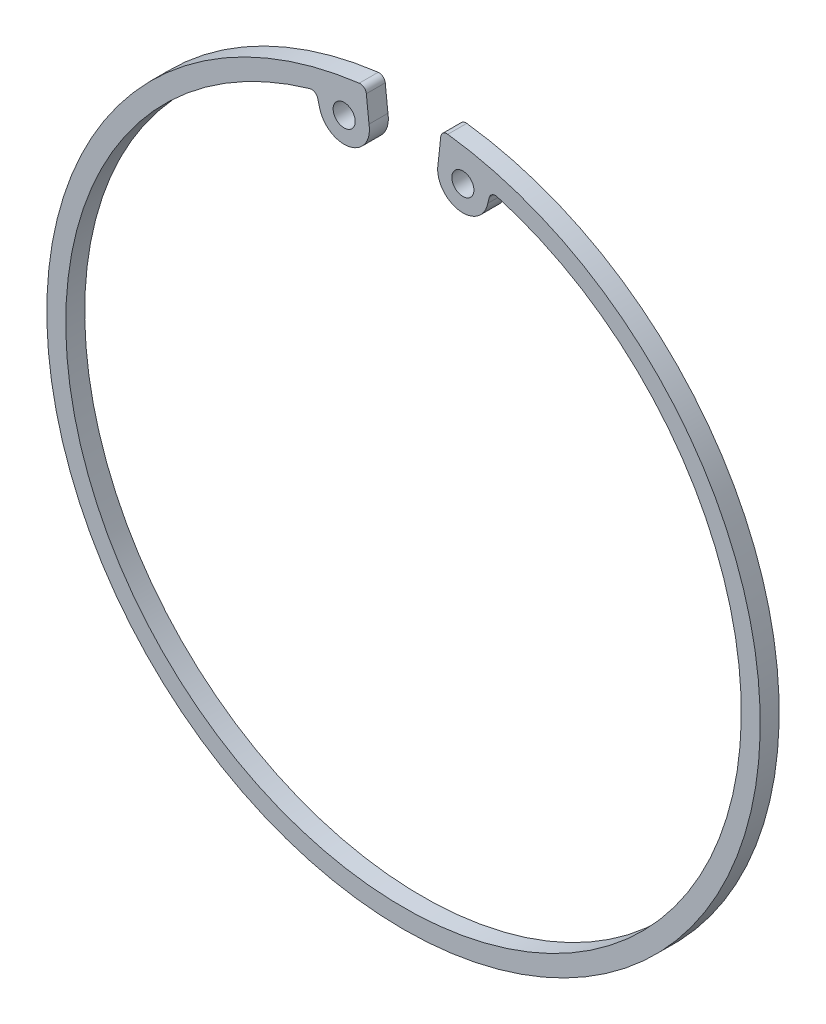
from build123d import *

# Parameters (mm, degrees)
SCHIZZO1_R                   = 1.75
ESTRUSIONE_ESTRUSIONE1_DEPTH = 3


with BuildPart() as part:
    # Schizzo1 → Estrusione-Estrusione1 (new body)
    with BuildSketch(Plane.XY):
        with BuildLine():
            Line((-5.892848523, 55.177208486), (-5.574209769, 52.193660395))
            Line((-5.574209769, 52.193660395), (-5.469026549, 51.208785854))
            ThreePointArc((-5.469026549, 51.208785854), (-8.668981909, 46.543993716), (-13.333774047, 49.743949076))
            Line((-13.333774047, 49.743949076), (-13.590216265, 50.700651099))
            ThreePointArc((-13.590216265, 50.700651099), (-14.064469506, 51.31253651), (-14.833377583, 51.402537967))
            ThreePointArc((-14.833377583, 51.402537967), (0, -53.5), (14.833377583, 51.402537967))
            ThreePointArc((14.833377583, 51.402537967), (14.064469506, 51.31253651), (13.590216265, 50.700651099))
            Line((13.590216265, 50.700651099), (13.333774047, 49.743949076))
            ThreePointArc((13.333774047, 49.743949076), (8.668981909, 46.543993716), (5.469026549, 51.208785854))
            Line((5.469026549, 51.208785854), (5.574209769, 52.193660395))
            Line((5.574209769, 52.193660395), (5.892848523, 55.177208486))
            ThreePointArc((5.892848523, 55.177208486), (6.266213098, 55.854839586), (7.011287463, 56.063284314))
            ThreePointArc((7.011287463, 56.063284314), (0, -56.5), (-7.011287463, 56.063284314))
            ThreePointArc((-7.011287463, 56.063284314), (-6.266213098, 55.854839586), (-5.892848523, 55.177208486))
        make_face()
        with Locations((-9.401400298, 50.476367465)):
            Circle(SCHIZZO1_R, mode=Mode.SUBTRACT)
        with Locations((9.401400298, 50.476367465)):
            Circle(SCHIZZO1_R, mode=Mode.SUBTRACT)
    extrude(amount=ESTRUSIONE_ESTRUSIONE1_DEPTH)


solid = part.part
